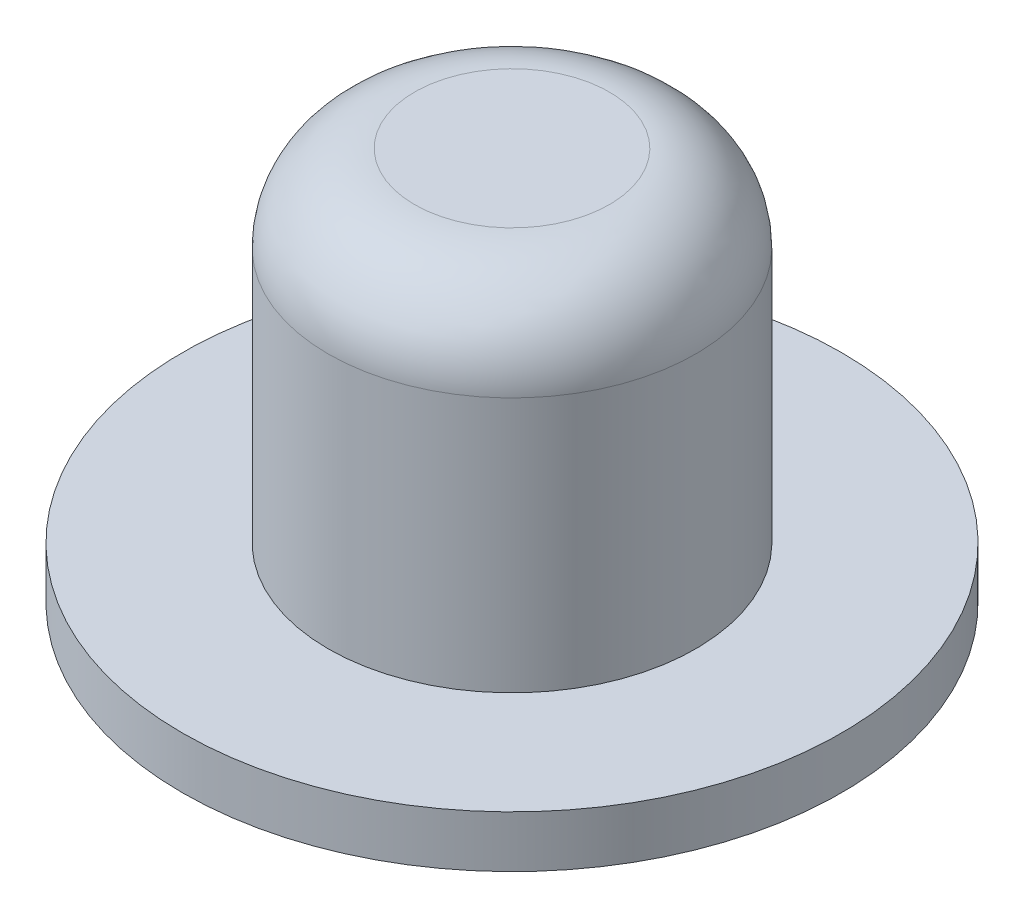
from build123d import *

# Parameters (mm, degrees)
SKETCH1_R           = 19.1
SKETCH1_R_2         = 10.65
BOSS_EXTRUDE1_DEPTH = 3
SKETCH1_2_R         = 10.65
BOSS_EXTRUDE2_DEPTH = 22.8
FILLET1_R           = 5


with BuildPart() as part:
    # Sketch1 → Boss-Extrude1 (new body)
    with BuildSketch(Plane(origin=(0, 0, 0), x_dir=(1, 0, 0), z_dir=(0, 1, 0))):
        Circle(SKETCH1_R)
        Circle(SKETCH1_R_2, mode=Mode.SUBTRACT)
    extrude(amount=BOSS_EXTRUDE1_DEPTH)

    # Sketch1_2 → Boss-Extrude2 (add)
    with BuildSketch(Plane(origin=(0, 0, 0), x_dir=(1, 0, 0), z_dir=(0, 1, 0))):
        Circle(SKETCH1_2_R)
    extrude(amount=BOSS_EXTRUDE2_DEPTH)

    # Fillet1
    fillet1_edges = [part.edges().sort_by_distance(p)[0] for p in [
        (-10.65, 22.8, 0),
    ]]
    fillet(fillet1_edges, radius=FILLET1_R)


solid = part.part
